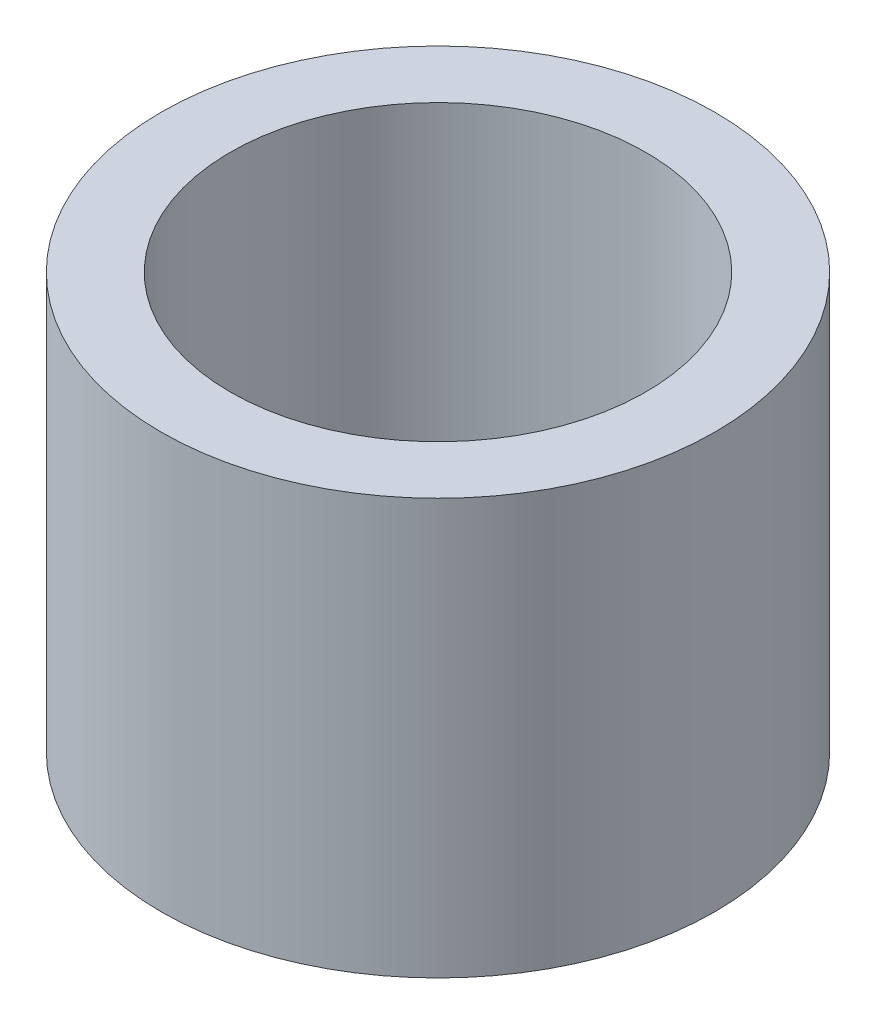
from build123d import *

# Parameters (mm, degrees)
SKETCH1_R           = 10
BOSS_EXTRUDE1_DEPTH = 15
SKETCH2_R           = 7.5
CUT_EXTRUDE1_DEPTH  = 12.5


with BuildPart() as part:
    # Sketch1 → Boss-Extrude1 (new body)
    with BuildSketch(Plane(origin=(0, 0, 0), x_dir=(1, 0, 0), z_dir=(0, 1, 0))):
        with Locations((-5.425115689, 4.310704304)):
            Circle(SKETCH1_R)
    extrude(amount=BOSS_EXTRUDE1_DEPTH)

    # Sketch2 → Cut-Extrude1 (cut)
    with BuildSketch(Plane(origin=(0, 15, 0), x_dir=(1, 0, 0), z_dir=(0, 1, 0))):
        with Locations((-5.425115689, 4.310704304)):
            Circle(SKETCH2_R)
    extrude(amount=-CUT_EXTRUDE1_DEPTH, mode=Mode.SUBTRACT)


solid = part.part
